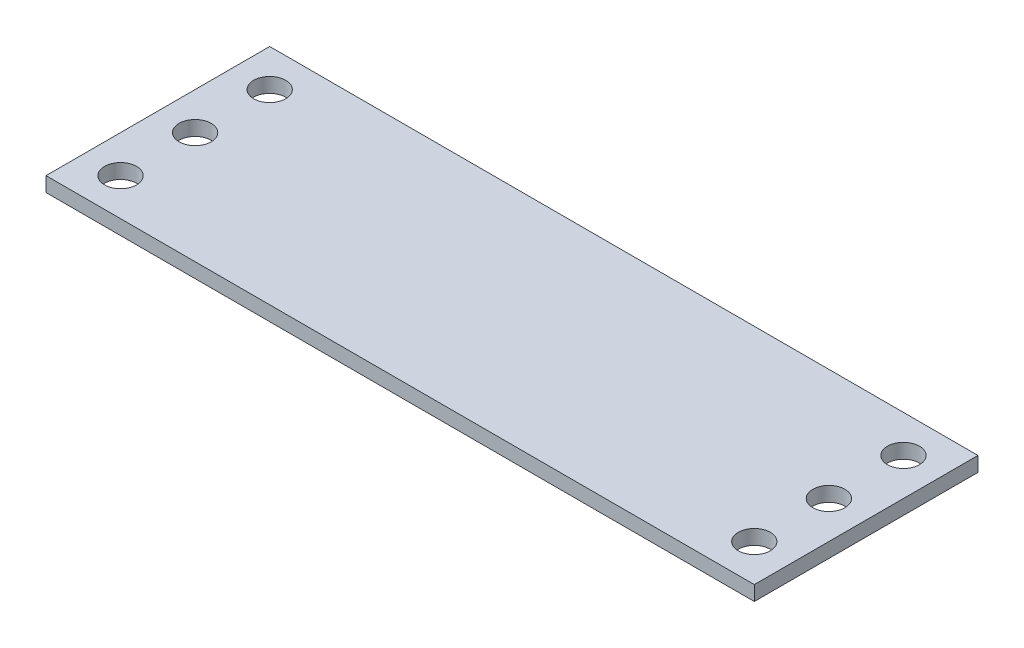
from build123d import *

# Parameters (mm, degrees)
SKETCH1_W           = 48.26
SKETCH1_H           = 15.24
BOSS_EXTRUDE1_DEPTH = 1
SKETCH2_R           = 1.0922
CUT_EXTRUDE1_DEPTH  = 1


with BuildPart() as part:
    # Sketch1 → Boss-Extrude1 (new body)
    with BuildSketch(Plane(origin=(0, 0, 0), x_dir=(1, 0, 0), z_dir=(0, 1, 0))):
        Rectangle(SKETCH1_W, SKETCH1_H)
    extrude(amount=BOSS_EXTRUDE1_DEPTH)

    # Sketch2 → Cut-Extrude1 (cut)
    with BuildSketch(Plane(origin=(0, 1, 0), x_dir=(1, 0, 0), z_dir=(0, 1, 0))):
        with Locations((-21.59, 5.08)):
            Circle(SKETCH2_R)
        with Locations((-21.59, 0)):
            Circle(SKETCH2_R)
        with Locations((-21.59, -5.08)):
            Circle(SKETCH2_R)
        with Locations((21.59, -5.08)):
            Circle(SKETCH2_R)
        with Locations((21.59, 0)):
            Circle(SKETCH2_R)
        with Locations((21.59, 5.08)):
            Circle(SKETCH2_R)
    extrude(amount=-CUT_EXTRUDE1_DEPTH, mode=Mode.SUBTRACT)


solid = part.part
